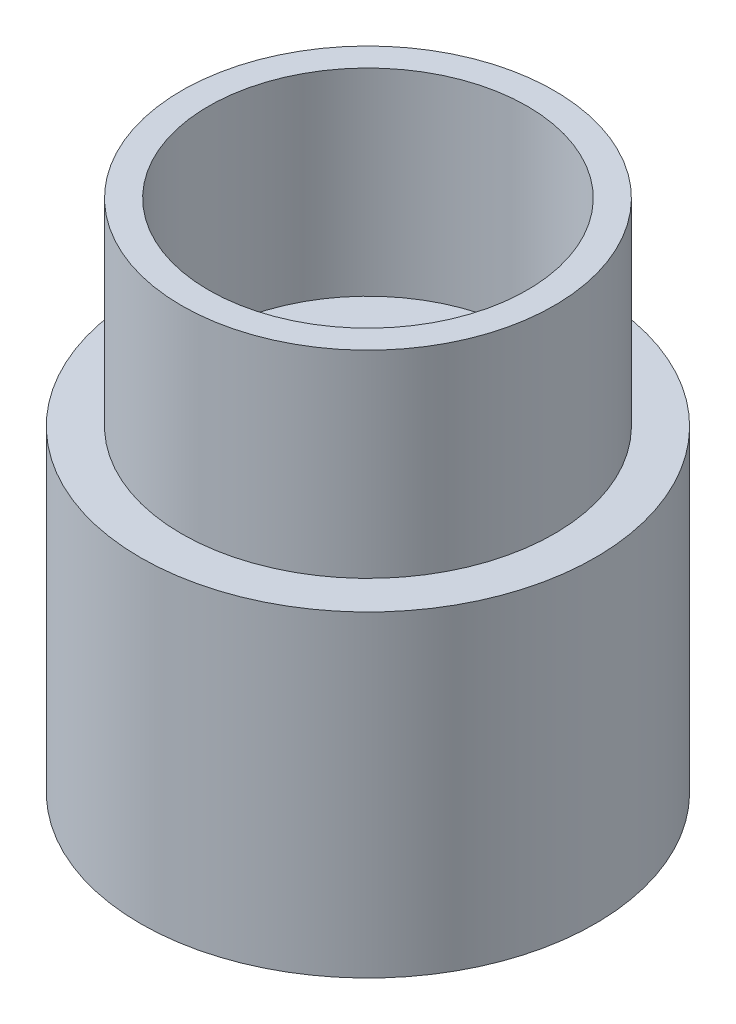
from build123d import *

# Parameters (mm, degrees)
CROQUIS1_R              = 11.05
CROQUIS1_R_2            = 9.05
SALIENTE_EXTRUIR1_DEPTH = 9.4
CROQUIS2_R              = 11.05
SALIENTE_EXTRUIR2_DEPTH = 6
CROQUIS3_R              = 9.05
CROQUIS3_R_2            = 7.74
SALIENTE_EXTRUIR3_DEPTH = 9.6
CROQUIS4_R              = 3.05
CORTAR_EXTRUIR1_DEPTH   = 9.6
CROQUIS5_R              = 9.15
CORTAR_EXTRUIR2_DEPTH   = 9.4


with BuildPart() as part:
    # Croquis1 → Saliente-Extruir1 (new body)
    with BuildSketch(Plane(origin=(0, 0, 0), x_dir=(1, 0, 0), z_dir=(0, 1, 0))):
        Circle(CROQUIS1_R)
        Circle(CROQUIS1_R_2, mode=Mode.SUBTRACT)
    extrude(amount=-SALIENTE_EXTRUIR1_DEPTH)

    # Croquis2 → Saliente-Extruir2 (add)
    with BuildSketch(Plane(origin=(0, 0, 0), x_dir=(1, 0, 0), z_dir=(0, 1, 0))):
        Circle(CROQUIS2_R)
    extrude(amount=SALIENTE_EXTRUIR2_DEPTH)

    # Croquis3 → Saliente-Extruir3 (add)
    with BuildSketch(Plane(origin=(0, 6, 0), x_dir=(1, 0, 0), z_dir=(0, 1, 0))):
        Circle(CROQUIS3_R)
        Circle(CROQUIS3_R_2, mode=Mode.SUBTRACT)
    extrude(amount=SALIENTE_EXTRUIR3_DEPTH)

    # Croquis4 → Cortar-Extruir1 (cut)
    with BuildSketch(Plane(origin=(0, 6, 0), x_dir=(1, 0, 0), z_dir=(0, 1, 0))):
        Circle(CROQUIS4_R)
    extrude(amount=-CORTAR_EXTRUIR1_DEPTH, mode=Mode.SUBTRACT)

    # Croquis5 → Cortar-Extruir2 (cut)
    with BuildSketch(Plane.XZ.offset(9.4)):
        Circle(CROQUIS5_R)
    extrude(amount=-CORTAR_EXTRUIR2_DEPTH, mode=Mode.SUBTRACT)

    # Croquis6 → Cortar-Revolución1 (revolve, cut)
    with BuildSketch(Plane.XY):
        Polygon((-9.15, 0), (-7.643411501, 1.506588499), (-5.172223625, 1.506588499), (-3.05, 6), (0, 6), (0, 1.506588499), (0, 0), align=None)
    revolve(axis=Axis((0, 1.506588499, 0), (0, -1, 0)), mode=Mode.SUBTRACT)


solid = part.part
